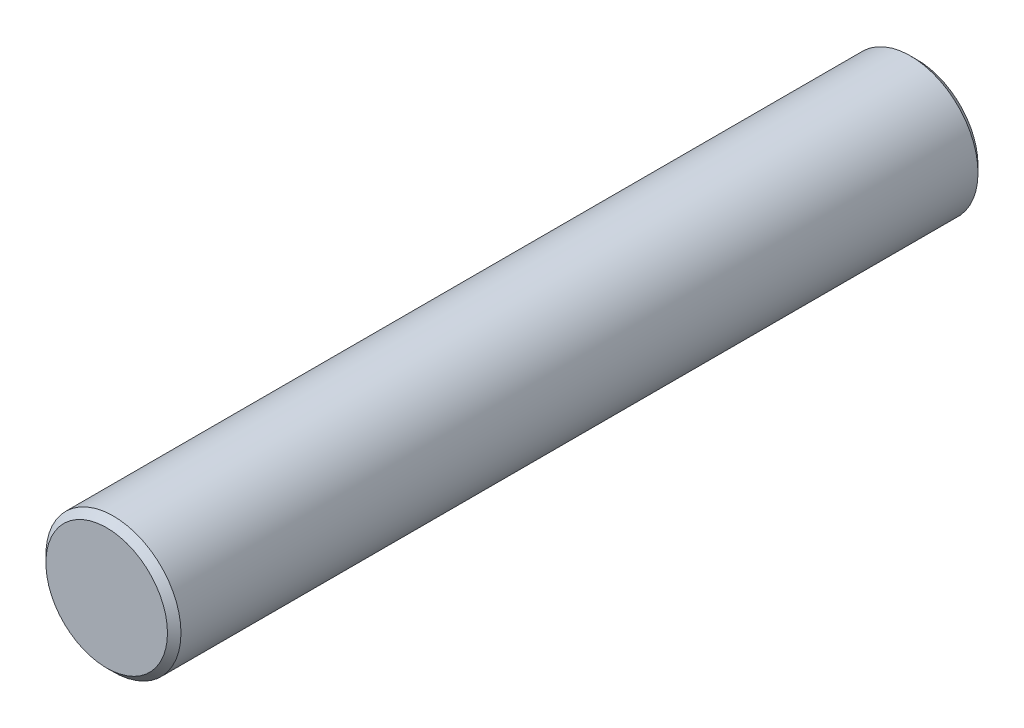
from build123d import *

# Parameters (mm, degrees)
ESQUISSE1_R          = 2.5
BASE_EXTRUSION_DEPTH = 30
CHANFREIN1_SIZE      = 0.25


with BuildPart() as part:
    # Esquisse1 → Base-Extrusion (new body)
    with BuildSketch(Plane.XY):
        Circle(ESQUISSE1_R)
    extrude(amount=BASE_EXTRUSION_DEPTH)

    # Chanfrein1
    chanfrein1_edges = [part.edges().sort_by_distance(p)[0] for p in [
        (-2.5, 0, 0),
        (-2.5, 0, 30),
    ]]
    chamfer(chanfrein1_edges, length=CHANFREIN1_SIZE)


solid = part.part
